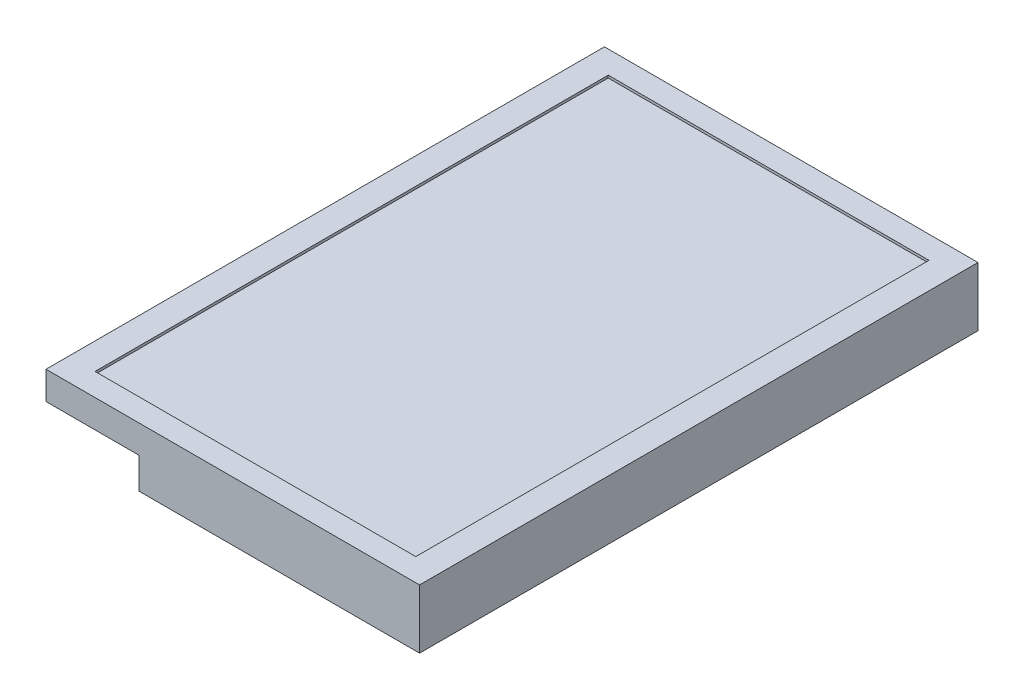
from build123d import *

# Parameters (mm, degrees)
SKETCH_1_W          = 297
SKETCH_1_H          = 444
EXTRUDE_1_DEPTH     = 47
SKETCH_2_W          = 255
SKETCH_2_H          = 408
CUT_EXTRUDE_1_DEPTH = 2
SKETCH_3_W          = 74
SKETCH_3_H          = 444
CUT_EXTRUDE_2_DEPTH = 24.736842105


with BuildPart() as part:
    # 草圖1 → 填料-伸長1 (new body)
    with BuildSketch(Plane(origin=(0, 0, 0), x_dir=(1, 0, 0), z_dir=(0, 1, 0))):
        Rectangle(SKETCH_1_W, SKETCH_1_H)
    extrude(amount=EXTRUDE_1_DEPTH)

    # 草圖2 → 除料-伸長1 (cut)
    with BuildSketch(Plane(origin=(0, 47, 0), x_dir=(1, 0, 0), z_dir=(0, 1, 0))):
        Rectangle(SKETCH_2_W, SKETCH_2_H)
    extrude(amount=-CUT_EXTRUDE_1_DEPTH, mode=Mode.SUBTRACT)

    # 草圖3 → 除料-伸長2 (cut)
    with BuildSketch(Plane.XZ):
        with Locations((-111.5, 0)):
            Rectangle(SKETCH_3_W, SKETCH_3_H)
    extrude(amount=-CUT_EXTRUDE_2_DEPTH, mode=Mode.SUBTRACT)


solid = part.part
